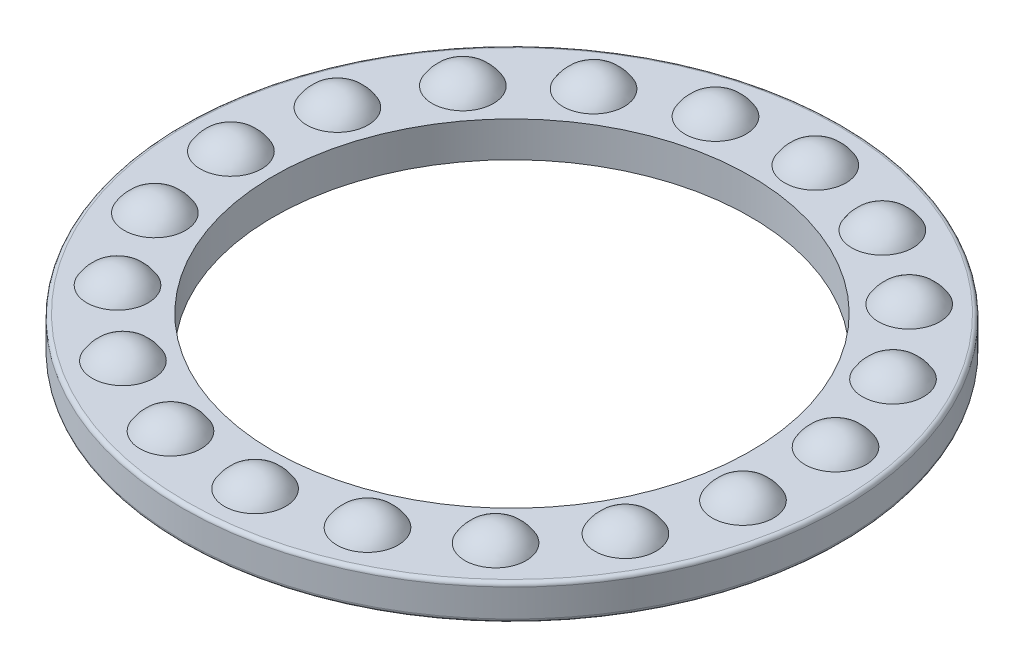
from build123d import *

# Parameters (mm, degrees)
SKETCH1_R           = 85
SKETCH1_R_2         = 61.5
BOSS_EXTRUDE1_DEPTH = 9.13
FILLET2_R           = 1
CIRPATTERN1_COUNT   = 19


with BuildPart() as part:
    # Sketch1 → Boss-Extrude1 (new body)
    with BuildSketch(Plane(origin=(0, 0, 0), x_dir=(1, 0, 0), z_dir=(0, 1, 0))):
        Circle(SKETCH1_R)
        Circle(SKETCH1_R_2, mode=Mode.SUBTRACT)
    extrude(amount=BOSS_EXTRUDE1_DEPTH)

    # Fillet2
    fillet2_edges = [part.edges().sort_by_distance(p)[0] for p in [
        (-85, 0, 0),
        (-85, 9.13, 0),
    ]]
    fillet(fillet2_edges, radius=FILLET2_R)

    # Sketch3 → Revolve1 (revolve)
    with BuildSketch(Plane.XY):
        with BuildLine():
            Line((-72.5, -4.565), (-72.5, 13.695))
            ThreePointArc((-72.5, 13.695), (-63.37, 4.565), (-72.5, -4.565))
        make_face()
    revolve1 = revolve(axis=Axis((-72.5, -4.565, 0), (0, 1, 0)))

    # CirPattern1: Revolve1 ×19 about axis
    cirpattern1_axis = Axis((0, 9.13, 0), (0, -1, 0))
    for i in range(1, CIRPATTERN1_COUNT):
        add(revolve1.rotate(cirpattern1_axis, i * 360 / CIRPATTERN1_COUNT))


solid = part.part
